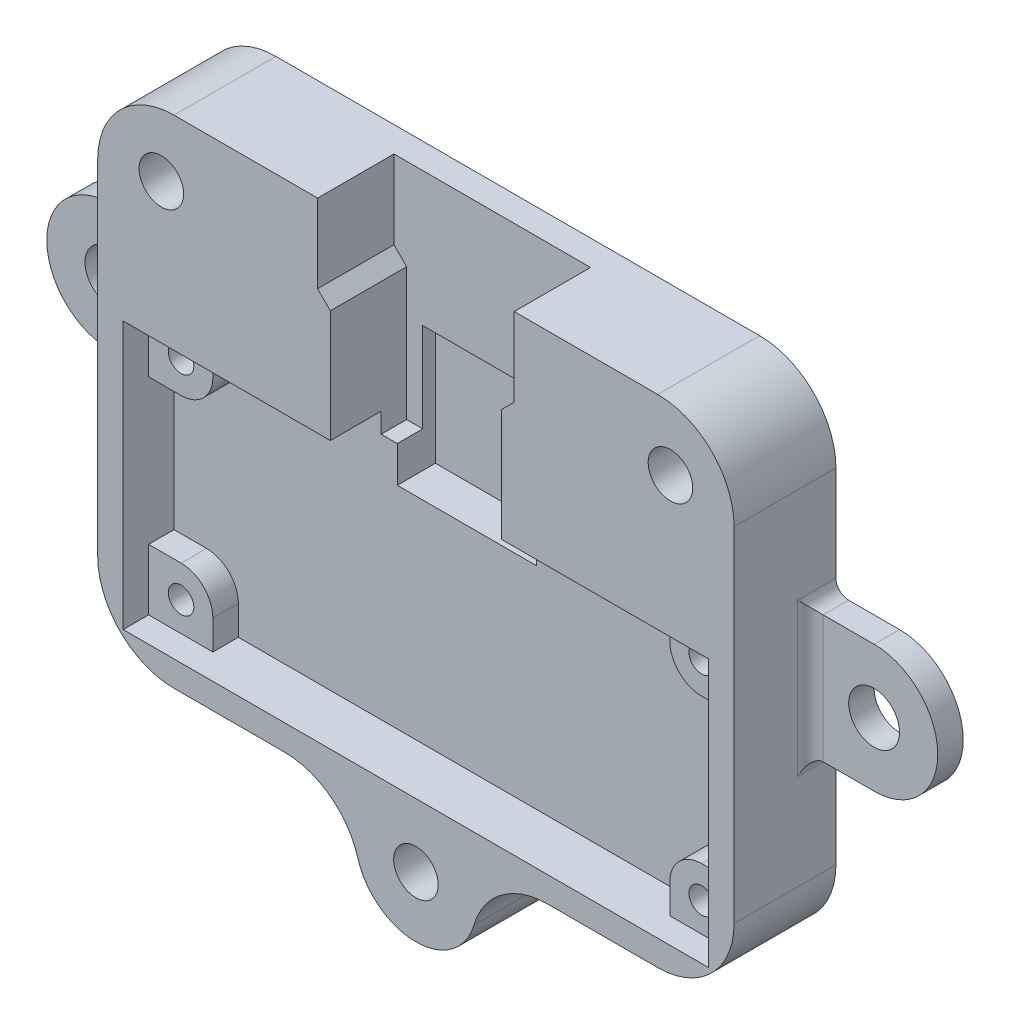
from build123d import *

# Parameters (mm, degrees)
SKETCH1_R           = 1.75
BOSS_EXTRUDE1_DEPTH = 8
SKETCH2_W           = 46
SKETCH2_H           = 21
CUT_EXTRUDE1_DEPTH  = 2
SKETCH3_R           = 1
CUT_EXTRUDE2_DEPTH  = 2
CUT_EXTRUDE3_DEPTH  = 6
SKETCH5_W           = 10.927537962
SKETCH5_H           = 9.870451426
CUT_EXTRUDE4_DEPTH  = 7
FILLET4_R           = 6
CHAMFER2_SIZE       = 1
SKETCH7_R           = 2
BOSS_EXTRUDE2_DEPTH = 2
FILLET5_R           = 1


with BuildPart() as part:
    # Sketch1 → Boss-Extrude1 (new body)
    with BuildSketch(Plane.XY):
        with BuildLine():
            Line((-4.75, -42), (-4.75, -39))
            Line((-4.75, -39), (-25, -39))
            Line((-25, -39), (-25, 0))
            Line((-25, 0), (25, 0))
            Line((25, 0), (25, -39))
            Line((25, -39), (4.75, -39))
            Line((4.75, -39), (4.75, -42))
            ThreePointArc((4.75, -42), (0, -46.75), (-4.75, -42))
        make_face()
        with Locations((-20, -5)):
            Circle(SKETCH1_R, mode=Mode.SUBTRACT)
        with Locations((20, -5)):
            Circle(SKETCH1_R, mode=Mode.SUBTRACT)
        with Locations((0, -42)):
            Circle(SKETCH1_R, mode=Mode.SUBTRACT)
    extrude(amount=BOSS_EXTRUDE1_DEPTH)

    # Sketch2 → Cut-Extrude1 (cut)
    with BuildSketch(Plane.XY.offset(8)):
        with Locations((0, -26.5)):
            Rectangle(SKETCH2_W, SKETCH2_H)
    extrude(amount=-CUT_EXTRUDE1_DEPTH, mode=Mode.SUBTRACT)

    # Sketch3 → Cut-Extrude2 (cut)
    with BuildSketch(Plane.XY.offset(6)):
        with Locations((-20.45, -18.3)):
            Circle(SKETCH3_R)
        with Locations((20.45, -18.3)):
            Circle(SKETCH3_R)
        with Locations((20.45, -34.7)):
            Circle(SKETCH3_R)
        with Locations((-20.45, -34.7)):
            Circle(SKETCH3_R)
        with BuildLine():
            Line((-17.95, -18.3), (-17.95, -16))
            Line((-17.95, -16), (17.95, -16))
            Line((17.95, -16), (17.95, -18.3))
            ThreePointArc((17.95, -18.3), (18.682233047, -20.067766953), (20.45, -20.8))
            Line((20.45, -20.8), (23, -20.8))
            Line((23, -20.8), (23, -32.2))
            Line((23, -32.2), (20.45, -32.2))
            ThreePointArc((20.45, -32.2), (18.682233047, -32.932233047), (17.95, -34.7))
            Line((17.95, -34.7), (17.95, -37))
            Line((17.95, -37), (-17.95, -37))
            Line((-17.95, -37), (-17.95, -34.7))
            ThreePointArc((-17.95, -34.7), (-18.682233047, -32.932233047), (-20.45, -32.2))
            Line((-20.45, -32.2), (-23, -32.2))
            Line((-23, -32.2), (-23, -20.8))
            Line((-23, -20.8), (-20.45, -20.8))
            ThreePointArc((-20.45, -20.8), (-18.682233047, -20.067766953), (-17.95, -18.3))
        make_face()
    extrude(amount=-CUT_EXTRUDE2_DEPTH, mode=Mode.SUBTRACT)

    # Sketch4 → Cut-Extrude3 (cut)
    with BuildSketch(Plane.XY.offset(8)):
        Polygon((-7.723, 0), (-7.723, -6.1725), (-6.723, -7.1725), (-6.723, -17.5725), (6.723, -17.5725), (6.723, -7.1725), (7.723, -6.1725), (7.723, 0), align=None)
    extrude(amount=-CUT_EXTRUDE3_DEPTH, mode=Mode.SUBTRACT)

    # Sketch5 → Cut-Extrude4 (cut)
    with BuildSketch(Plane.XY.offset(8)):
        with Locations((0, -15.479727473)):
            Rectangle(SKETCH5_W, SKETCH5_H)
    extrude(amount=-CUT_EXTRUDE4_DEPTH, mode=Mode.SUBTRACT)

    # Fillet4
    fillet4_edges = [part.edges().sort_by_distance(p)[0] for p in [
        (25, -39, 4),
        (4.75, -39, 4),
        (-25, -39, 4),
        (-4.75, -39, 4),
        (25, 0, 4),
        (-25, 0, 4),
    ]]
    fillet(fillet4_edges, radius=FILLET4_R)

    # Chamfer2
    chamfer2_edges = [part.edges().sort_by_distance(p)[0] for p in [
        (-1.75, -42, 0),
        (-21.75, -5, 0),
        (18.25, -5, 0),
    ]]
    chamfer(chamfer2_edges, length=CHAMFER2_SIZE)

    # Sketch7 → Boss-Extrude2 (add)
    with BuildSketch(Plane(origin=(0, 0, 0), x_dir=(-1, 0, 0), z_dir=(0, 0, -1))):
        with BuildLine():
            Line((-25, -14.5), (-30, -14.5))
            ThreePointArc((-30, -14.5), (-35, -19.5), (-30, -24.5))
            Line((-30, -24.5), (-25, -24.5))
            Line((-25, -24.5), (-25, -14.5))
        make_face()
        with Locations((-30, -19.5)):
            Circle(SKETCH7_R, mode=Mode.SUBTRACT)
        with BuildLine():
            Line((30, -14.5), (25, -14.5))
            Line((25, -14.5), (25, -24.5))
            Line((25, -24.5), (30, -24.5))
            ThreePointArc((30, -24.5), (35, -19.5), (30, -14.5))
        make_face()
        with Locations((30, -19.5)):
            Circle(SKETCH7_R, mode=Mode.SUBTRACT)
    extrude(amount=-BOSS_EXTRUDE2_DEPTH)

    # Fillet5
    fillet5_edges = [part.edges().sort_by_distance(p)[0] for p in [
        (25, -14.5, 1),
        (25, -24.5, 1),
        (25, -19.5, 2),
        (-25, -24.5, 1),
        (-25, -14.5, 1),
        (-25, -19.5, 2),
    ]]
    fillet(fillet5_edges, radius=FILLET5_R)


solid = part.part
